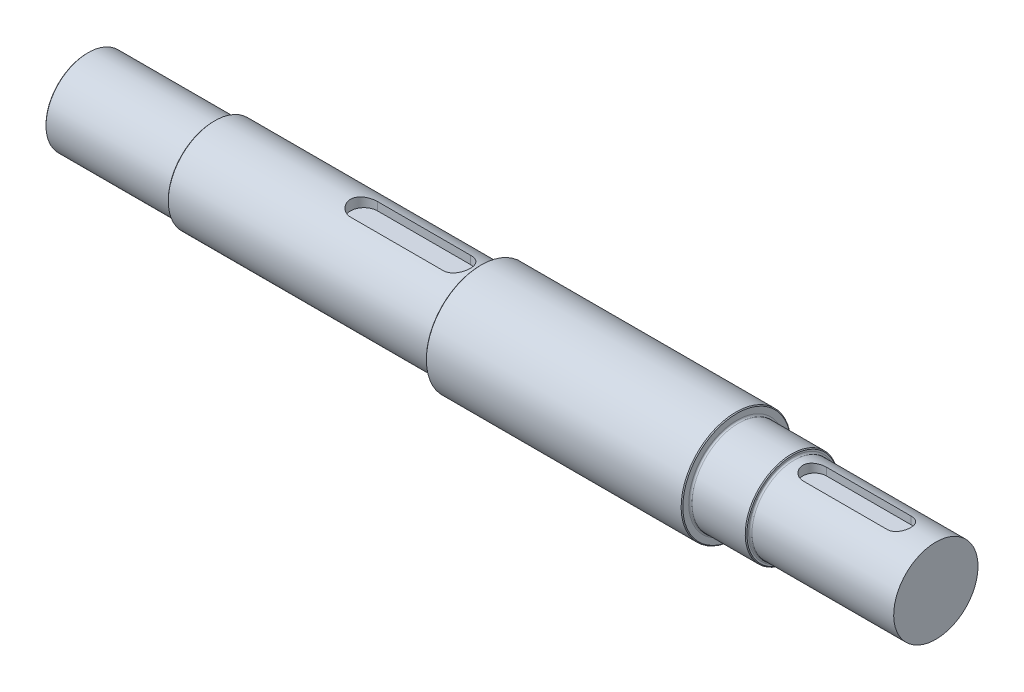
from build123d import *

# Parameters (mm, degrees)
CHAMFER1_SIZE      = 0.5
FILLET1_R          = 1
CUT_EXTRUDE1_DEPTH = 6
CUT_EXTRUDE2_DEPTH = 5.5


with BuildPart() as part:
    # Sketch1 → Revolve1 (revolve)
    with BuildSketch(Plane.XY):
        Polygon((-113.708057171, 0), (-113.708057171, 25), (-38.708057171, 25), (-38.708057171, 27.5), (119.291942829, 27.5), (119.291942829, 32.5), (271.291942829, 32.5), (271.291942829, 27.5), (304.291942829, 27.5), (304.291942829, 25), (389.291942829, 25), (389.291942829, 0), (178.819444444, 0), align=None)
    revolve(axis=Axis((178.819444444, 0, 0), (-1, 0, 0)))

    # Chamfer1
    chamfer1_edges = [part.edges().sort_by_distance(p)[0] for p in [
        (304.291942829, -27.5, 0),
        (271.291942829, -32.5, 0),
        (119.291942829, -32.5, 0),
        (-38.708057171, -27.5, 0),
        (-113.708057171, -25, 0),
    ]]
    chamfer(chamfer1_edges, length=CHAMFER1_SIZE)

    # Fillet1
    fillet1_edges = [part.edges().sort_by_distance(p)[0] for p in [
        (304.291942829, -25, 0),
        (271.291942829, -27.5, 0),
        (119.291942829, -27.5, 0),
        (-38.708057171, -25, 0),
    ]]
    fillet(fillet1_edges, radius=FILLET1_R)

    # Sketch3 → Cut-Extrude1 (cut)
    with BuildSketch(Plane(origin=(0, 27.5, 0), x_dir=(1, 0, 0), z_dir=(0, 1, 0))):
        with BuildLine():
            Line((50.328098338, 8), (105.328098338, 8))
            ThreePointArc((105.328098338, 8), (113.328098338, 0), (105.328098338, -8))
            Line((105.328098338, -8), (50.328098338, -8))
            ThreePointArc((50.328098338, -8), (42.328098338, 0), (50.328098338, 8))
        make_face()
    extrude(amount=-CUT_EXTRUDE1_DEPTH, mode=Mode.SUBTRACT)

    # Sketch4 → Cut-Extrude2 (cut)
    with BuildSketch(Plane(origin=(0, 25, 0), x_dir=(1, 0, 0), z_dir=(0, 1, 0))):
        with BuildLine():
            Line((317.435334748, 7), (367.435334748, 7))
            ThreePointArc((367.435334748, 7), (374.435334748, 0), (367.435334748, -7))
            Line((367.435334748, -7), (317.435334748, -7))
            ThreePointArc((317.435334748, -7), (310.435334748, 0), (317.435334748, 7))
        make_face()
    extrude(amount=-CUT_EXTRUDE2_DEPTH, mode=Mode.SUBTRACT)


solid = part.part
